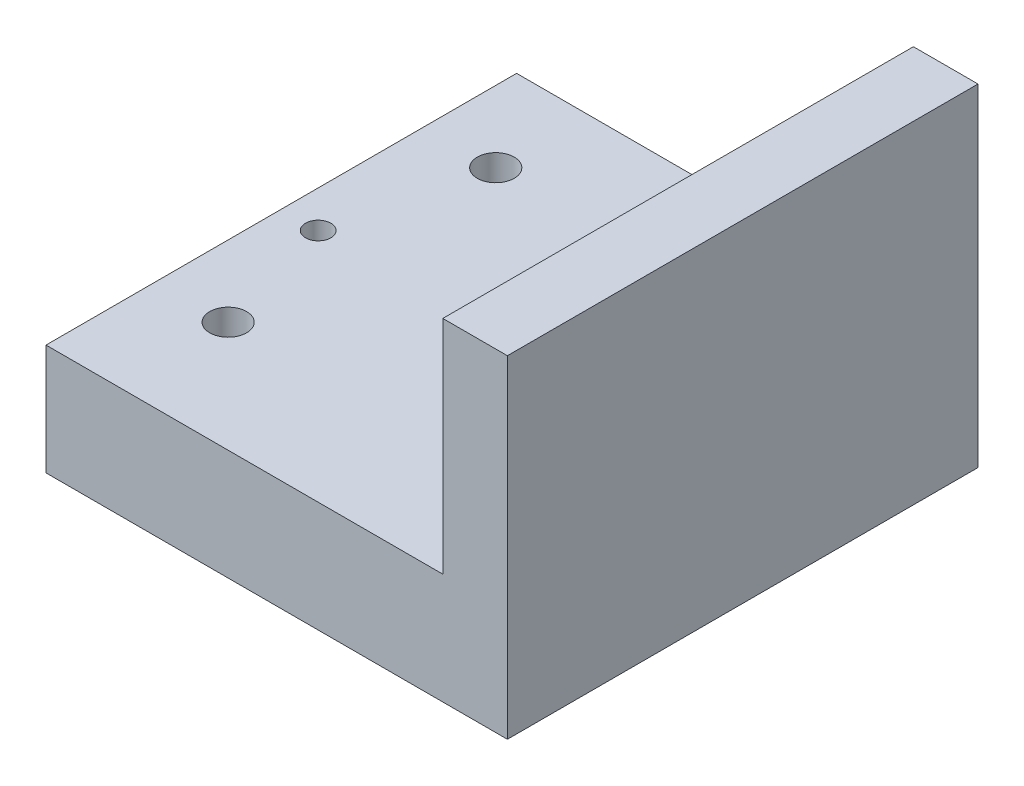
from build123d import *

# Parameters (mm, degrees)
SKETCH1_W                = 43
SKETCH1_H                = 51
BOSS_EXTRUDE1_DEPTH      = 12
SKETCH2_W                = 7
SKETCH2_H                = 51
BOSS_EXTRUDE2_DEPTH      = 24
BOSS_EXTRUDE2_DEPTH_BACK = 12
SKETCH3_R                = 1.375
SKETCH3_R_2              = 2
CUT_EXTRUDE1_DEPTH       = 12


with BuildPart() as part:
    # Sketch1 → Boss-Extrude1 (new body)
    with BuildSketch(Plane(origin=(0, 0, 0), x_dir=(1, 0, 0), z_dir=(0, 1, 0))):
        Rectangle(SKETCH1_W, SKETCH1_H)
    extrude(amount=BOSS_EXTRUDE1_DEPTH)

    # Sketch2 → Boss-Extrude2 (add, two sides)
    with BuildSketch(Plane(origin=(0, 12, 0), x_dir=(1, 0, 0), z_dir=(0, 1, 0))) as boss_extrude2_sk:
        with Locations((25, 0)):
            Rectangle(SKETCH2_W, SKETCH2_H)
    extrude(amount=BOSS_EXTRUDE2_DEPTH)
    extrude(boss_extrude2_sk.sketch, amount=-BOSS_EXTRUDE2_DEPTH_BACK)

    # Sketch3 → Cut-Extrude1 (cut)
    with BuildSketch(Plane(origin=(0, 12, 0), x_dir=(1, 0, 0), z_dir=(0, 1, 0))):
        with Locations((17.5, 0)):
            Circle(SKETCH3_R)
        with Locations((-17.5, 0)):
            Circle(SKETCH3_R)
        with Locations((13.775, 15.513813063)):
            Circle(SKETCH3_R_2)
        with Locations((-13.775, 15.513813063)):
            Circle(SKETCH3_R_2)
        with Locations((13.775, -13.486186937)):
            Circle(SKETCH3_R_2)
        with Locations((-13.775, -13.486186937)):
            Circle(SKETCH3_R_2)
    extrude(amount=-CUT_EXTRUDE1_DEPTH, mode=Mode.SUBTRACT)


solid = part.part
